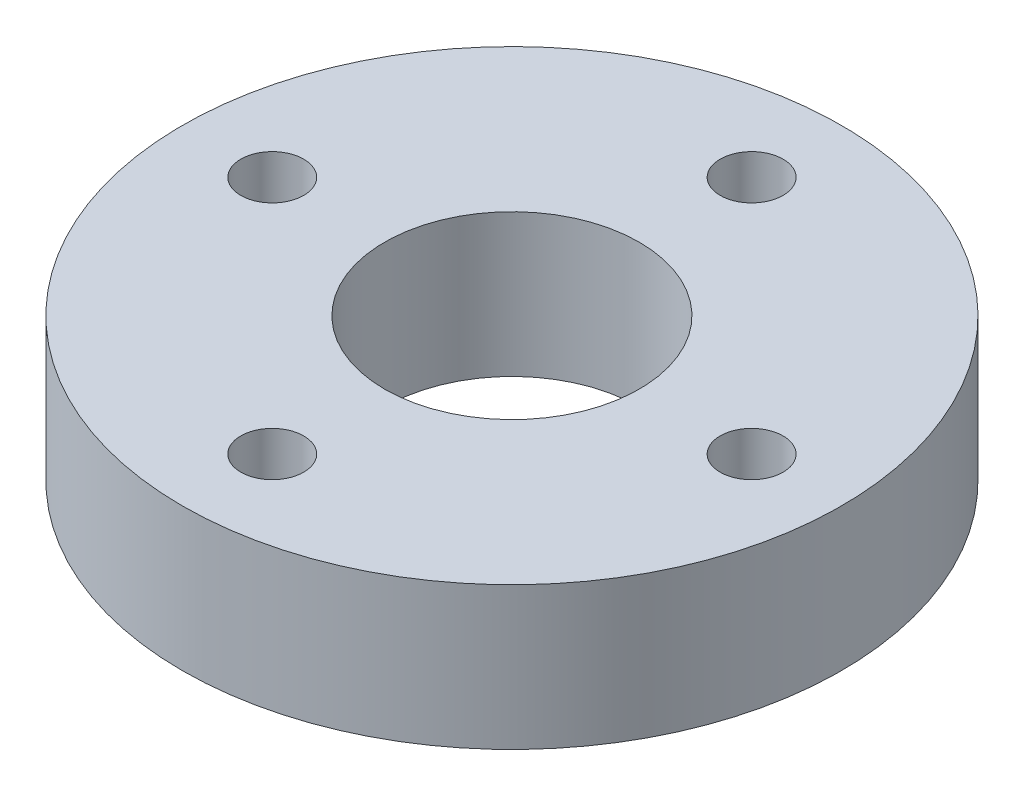
from build123d import *

# Parameters (mm, degrees)
SKETCH1_R           = 11
BOSS_EXTRUDE1_DEPTH = 4.7625
SKETCH2_R           = 1.05
CUT_EXTRUDE1_DEPTH  = 5.7625
SKETCH3_R           = 4.25
CUT_EXTRUDE2_DEPTH  = 5.7625


with BuildPart() as part:
    # Sketch1 → Boss-Extrude1 (new body)
    with BuildSketch(Plane(origin=(0, 0, 0), x_dir=(1, 0, 0), z_dir=(0, 1, 0))):
        Circle(SKETCH1_R)
    extrude(amount=BOSS_EXTRUDE1_DEPTH)

    # Sketch2 → Cut-Extrude1 (cut, through all)
    with BuildSketch(Plane(origin=(0, 4.7625, 0), x_dir=(-1, 0, 0), z_dir=(0, 1, 0))):
        with Locations((0, 8)):
            Circle(SKETCH2_R)
        with Locations((8, 0)):
            Circle(SKETCH2_R)
        with Locations((0, -8)):
            Circle(SKETCH2_R)
        with Locations((-8, 0)):
            Circle(SKETCH2_R)
    extrude(amount=-CUT_EXTRUDE1_DEPTH, mode=Mode.SUBTRACT)

    # Sketch3 → Cut-Extrude2 (cut, through all)
    with BuildSketch(Plane(origin=(0, 4.7625, 0), x_dir=(-1, 0, 0), z_dir=(0, 1, 0))):
        Circle(SKETCH3_R)
    extrude(amount=-CUT_EXTRUDE2_DEPTH, mode=Mode.SUBTRACT)


solid = part.part
